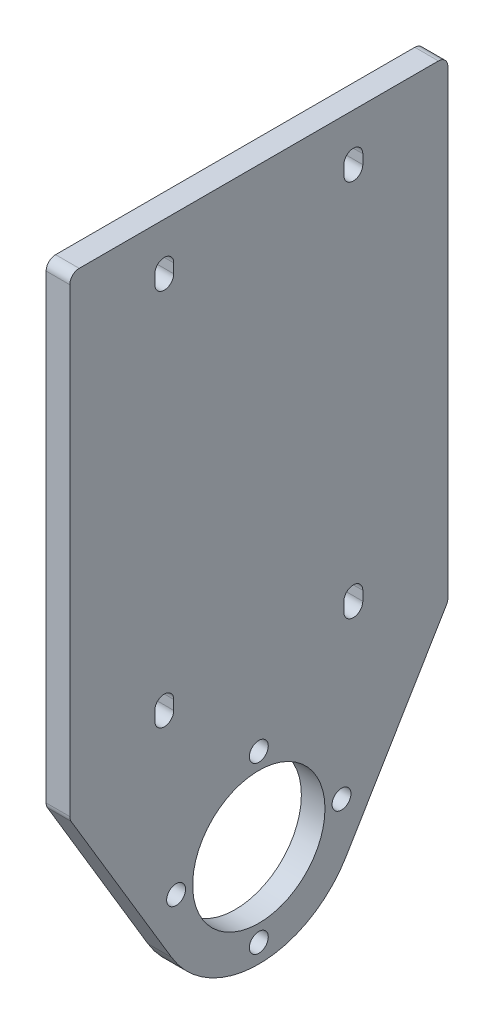
from build123d import *

# Parameters (mm, degrees)
SKETCH1_W           = 80
SKETCH1_H           = 100
SKETCH1_R           = 21.5
SKETCH1_R_2         = 14
SKETCH1_R_3         = 2
BOSS_EXTRUDE1_DEPTH = 5
FILLET1_R           = 2


with BuildPart() as part:
    # Sketch1 → Boss-Extrude1 (new body)
    with BuildSketch(Plane(origin=(0, 0, 0), x_dir=(0, 0, -1), z_dir=(1, 0, 0))):
        Rectangle(SKETCH1_W, SKETCH1_H)
        with BuildLine():
            ThreePointArc((22, -39), (20, -37), (18, -39))
            Line((18, -39), (18, -41))
            ThreePointArc((18, -41), (20, -43), (22, -41))
            Line((22, -41), (22, -39))
        make_face(mode=Mode.SUBTRACT)
        with BuildLine():
            ThreePointArc((-22, 39), (-20, 37), (-18, 39))
            Line((-18, 39), (-18, 41))
            ThreePointArc((-18, 41), (-20, 43), (-22, 41))
            Line((-22, 41), (-22, 39))
        make_face(mode=Mode.SUBTRACT)
        with BuildLine():
            Line((22, 41), (22, 39))
            ThreePointArc((22, 39), (20, 37), (18, 39))
            Line((18, 39), (18, 41))
            ThreePointArc((18, 41), (20, 43), (22, 41))
        make_face(mode=Mode.SUBTRACT)
        with BuildLine():
            Line((-22, -41), (-22, -39))
            ThreePointArc((-22, -39), (-20, -37), (-18, -39))
            Line((-18, -39), (-18, -41))
            ThreePointArc((-18, -41), (-20, -43), (-22, -41))
        make_face(mode=Mode.SUBTRACT)
        with BuildLine():
            Line((40, -50), (-40, -50))
            Line((-40, -50), (-18.452584301, -86.034134882))
            ThreePointArc((-18.452584301, -86.034134882), (-5.72361064, -54.275852702), (21.5, -75))
            ThreePointArc((21.5, -75), (20.724147298, -80.72361064), (18.452584301, -86.034134882))
            Line((18.452584301, -86.034134882), (40, -50))
        make_face()
        with Locations((0, -75)):
            Circle(SKETCH1_R)
        with Locations((0, -75)):
            Circle(SKETCH1_R_2, mode=Mode.SUBTRACT)
        with Locations((17.5, -75)):
            Circle(SKETCH1_R_3, mode=Mode.SUBTRACT)
        with Locations((0, -92.5)):
            Circle(SKETCH1_R_3, mode=Mode.SUBTRACT)
        with Locations((-17.5, -75)):
            Circle(SKETCH1_R_3, mode=Mode.SUBTRACT)
        with Locations((0, -57.5)):
            Circle(SKETCH1_R_3, mode=Mode.SUBTRACT)
    extrude(amount=BOSS_EXTRUDE1_DEPTH)

    # Fillet1
    fillet1_edges = [part.edges().sort_by_distance(p)[0] for p in [
        (2.5, -50, -40),
        (2.5, -50, 40),
        (2.5, 50, 40),
        (2.5, 50, -40),
    ]]
    fillet(fillet1_edges, radius=FILLET1_R)


solid = part.part
